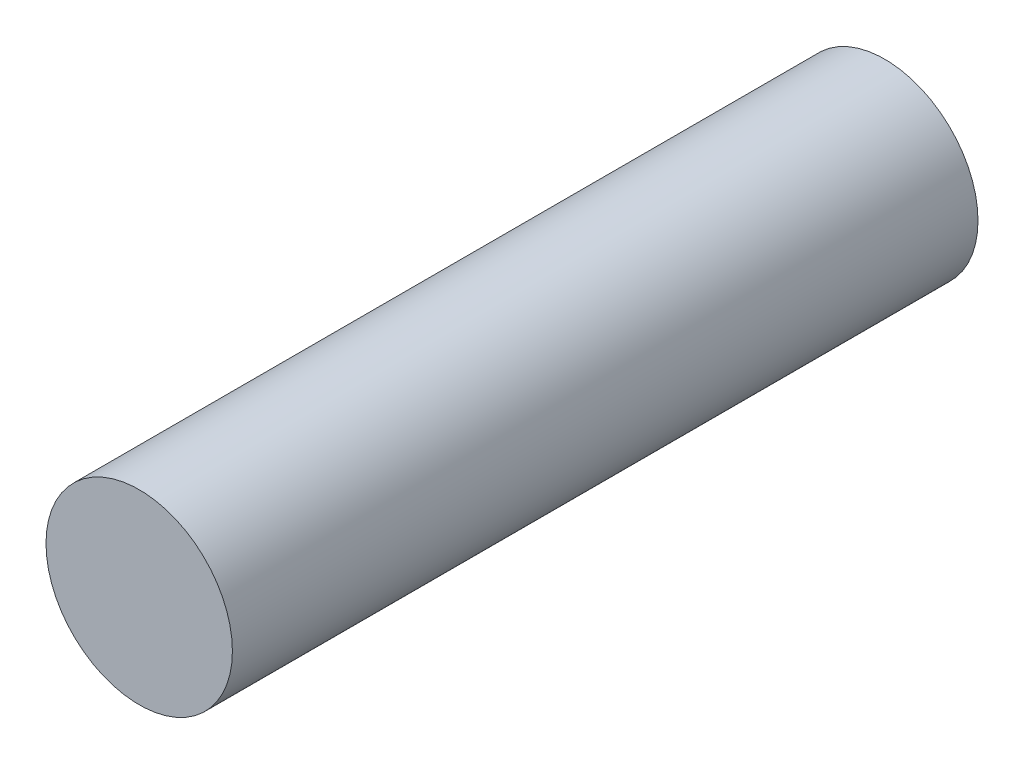
from build123d import *

# Parameters (mm, degrees)
SKETCH1_R           = 3.175
BOSS_EXTRUDE1_DEPTH = 25.4


with BuildPart() as part:
    # Sketch1 → Boss-Extrude1 (new body)
    with BuildSketch(Plane.XY):
        Circle(SKETCH1_R)
    extrude(amount=BOSS_EXTRUDE1_DEPTH)


solid = part.part
